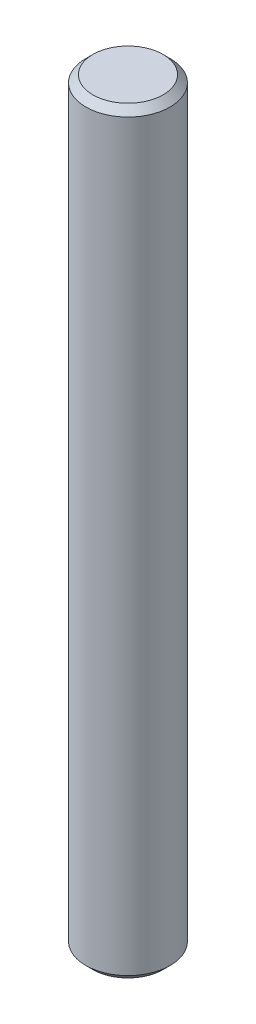
from build123d import *

# Parameters (mm, degrees)
ESBO_O2_R                = 3
RESSALTO_EXTRUS_O1_DEPTH = 27
CHANFRO1_SIZE            = 0.5


with BuildPart() as part:
    # Esboço2 → Ressalto-extrusão1 (new body, symmetric)
    with BuildSketch(Plane(origin=(0, 0, 0), x_dir=(1, 0, 0), z_dir=(0, 1, 0))):
        Circle(ESBO_O2_R)
    extrude(amount=RESSALTO_EXTRUS_O1_DEPTH, both=True)

    # Chanfro1
    chanfro1_edges = [part.edges().sort_by_distance(p)[0] for p in [
        (-3, -27, 0),
        (-3, 27, 0),
    ]]
    chamfer(chanfro1_edges, length=CHANFRO1_SIZE)


solid = part.part
